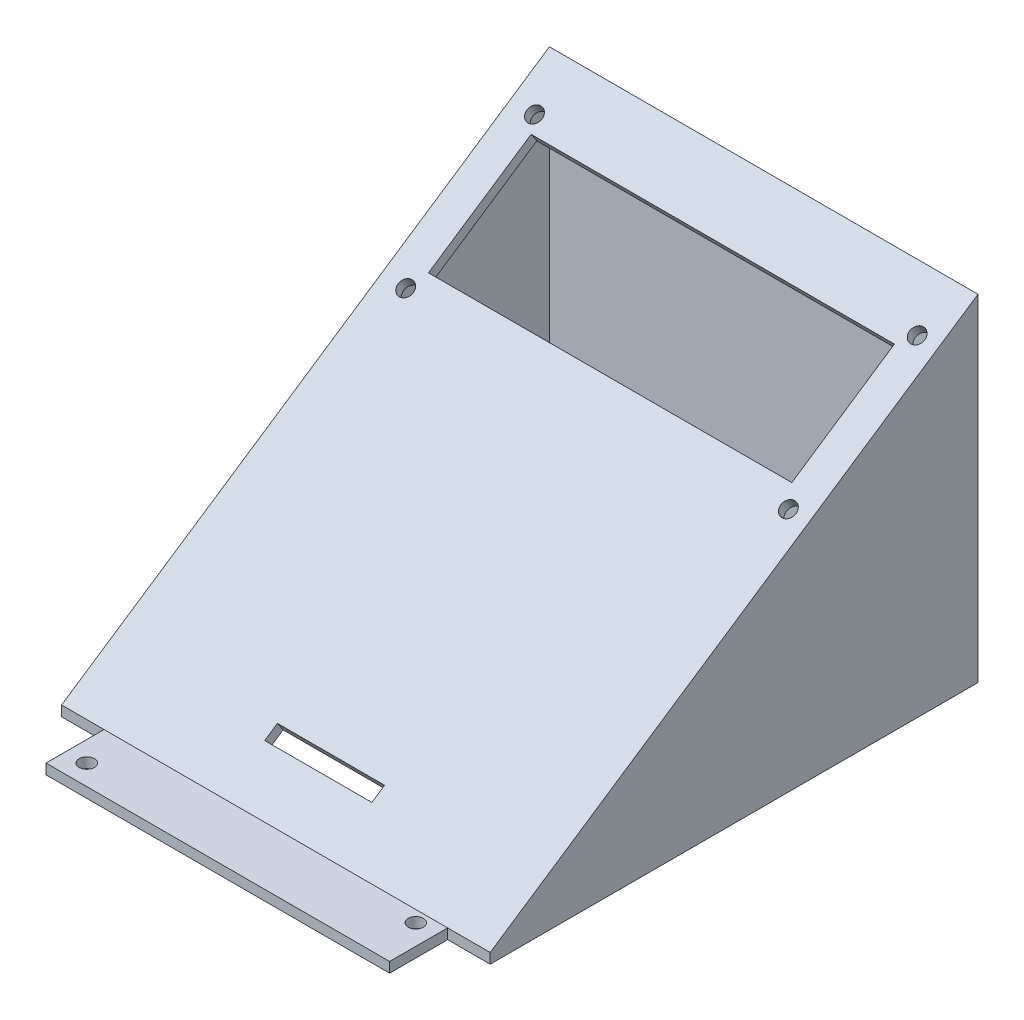
from build123d import *

# Parameters (mm, degrees)
SKETCH1_W           = 67.34
SKETCH1_H           = 113.06
SKETCH1_R           = 1.5
SKETCH1_W_2         = 55.34
SKETCH1_H_2         = 101.06
BOSS_EXTRUDE1_DEPTH = 2
BOSS_EXTRUDE2_DEPTH = 42
SKETCH4_W           = 55.34
SKETCH4_H           = 2
BOSS_EXTRUDE5_DEPTH = 11.970099
CUT_EXTRUDE1_REACH  = 60.174
SKETCH5_R           = 1.5
SKETCH5_W           = 71.2
SKETCH5_H           = 24.2
SKETCH5_W_2         = 21
SKETCH5_H_2         = 3
BOSS_EXTRUDE6_DEPTH = 2
SKETCH7_W           = 8.33
SKETCH7_H           = 95.603562999
BOSS_EXTRUDE7_DEPTH = 2
SKETCH8_W           = 55.34
SKETCH8_H           = 2
BOSS_EXTRUDE8_DEPTH = 2.076588


with BuildPart() as part:
    # Sketch1 → Boss-Extrude1 (new body)
    with BuildSketch(Plane(origin=(0, 0, 0), x_dir=(1, 0, 0), z_dir=(0, 1, 0))):
        with Locations((-64.664649644, -123.030692549)):
            Rectangle(SKETCH1_W, SKETCH1_H)
        with Locations((-34.994649644, -70.500692549)):
            Circle(SKETCH1_R, mode=Mode.SUBTRACT)
        with Locations((-94.334649644, -70.500692549)):
            Circle(SKETCH1_R, mode=Mode.SUBTRACT)
        with Locations((-94.334649644, -175.560692549)):
            Circle(SKETCH1_R, mode=Mode.SUBTRACT)
        with Locations((-34.994649644, -170.434906111)):
            Circle(SKETCH1_R, mode=Mode.SUBTRACT)
        with Locations((-64.664649644, -123.030692549)):
            Rectangle(SKETCH1_W_2, SKETCH1_H_2, mode=Mode.SUBTRACT)
    extrude(amount=BOSS_EXTRUDE1_DEPTH)

    # Sketch3 → Boss-Extrude2 (add, symmetric)
    with BuildSketch(Plane(origin=(-64.664649644, 0, 0), x_dir=(0, 0, -1), z_dir=(1, 0, 0))):
        Polygon((-161.590593962, 4), (-161.590593962, 2), (-168.180843703, 2), (-72.577280704, 65.913681963), (-72.577280704, 2), (-74.577280704, 2), (-74.577280704, 4), (-74.577280704, 62.1708574), align=None)
    extrude(amount=BOSS_EXTRUDE2_DEPTH, both=True)

    # Sketch4 → Boss-Extrude5 (add)
    with BuildSketch(Plane(origin=(0, 0, 173.560692549), x_dir=(-1, 0, 0), z_dir=(0, 0, -1))):
        with Locations((64.664649644, 1)):
            Rectangle(SKETCH4_W, SKETCH4_H)
    extrude(amount=BOSS_EXTRUDE5_DEPTH)

    # Sketch5 → Cut-Extrude1 (cut, up to next)
    with BuildSketch(Plane(origin=(0, 79.087200487, 52.872027158), x_dir=(1, 0, 0), z_dir=(0, 0.83133533, 0.555771148)), mode=Mode.PRIVATE) as cut_extrude1_sk1:
        with Locations((-26.824649644, -33.033134975)):
            Circle(SKETCH5_R)
    cut_extrude1_tool1 = extrude(cut_extrude1_sk1.sketch, amount=-CUT_EXTRUDE1_REACH, mode=Mode.PRIVATE) & part.part
    add(cut_extrude1_tool1.solids().sort_by_distance((-26.82465, 60.728337, 80.333639))[0], mode=Mode.SUBTRACT)
    # Sketch5 → Cut-Extrude1 (cut, up to next)
    with BuildSketch(Plane(origin=(0, 79.087200487, 52.872027158), x_dir=(1, 0, 0), z_dir=(0, 0.83133533, 0.555771148)), mode=Mode.PRIVATE) as cut_extrude1_sk2:
        with Locations((-26.824649644, -63.403134975)):
            Circle(SKETCH5_R)
    cut_extrude1_tool2 = extrude(cut_extrude1_sk2.sketch, amount=-CUT_EXTRUDE1_REACH, mode=Mode.PRIVATE) & part.part
    add(cut_extrude1_tool2.solids().sort_by_distance((-26.82465, 43.849567, 105.581293))[0], mode=Mode.SUBTRACT)
    # Sketch5 → Cut-Extrude1 (cut, up to next)
    with BuildSketch(Plane(origin=(0, 79.087200487, 52.872027158), x_dir=(1, 0, 0), z_dir=(0, 0.83133533, 0.555771148)), mode=Mode.PRIVATE) as cut_extrude1_sk3:
        with Locations((-101.824649644, -63.403134975)):
            Circle(SKETCH5_R)
    cut_extrude1_tool3 = extrude(cut_extrude1_sk3.sketch, amount=-CUT_EXTRUDE1_REACH, mode=Mode.PRIVATE) & part.part
    add(cut_extrude1_tool3.solids().sort_by_distance((-101.82465, 43.849567, 105.581293))[0], mode=Mode.SUBTRACT)
    # Sketch5 → Cut-Extrude1 (cut, up to next)
    with BuildSketch(Plane(origin=(0, 79.087200487, 52.872027158), x_dir=(1, 0, 0), z_dir=(0, 0.83133533, 0.555771148)), mode=Mode.PRIVATE) as cut_extrude1_sk4:
        with Locations((-101.824649644, -33.033134975)):
            Circle(SKETCH5_R)
    cut_extrude1_tool4 = extrude(cut_extrude1_sk4.sketch, amount=-CUT_EXTRUDE1_REACH, mode=Mode.PRIVATE) & part.part
    add(cut_extrude1_tool4.solids().sort_by_distance((-101.82465, 60.728337, 80.333639))[0], mode=Mode.SUBTRACT)
    # Sketch5 → Cut-Extrude1 (cut, up to next)
    with BuildSketch(Plane(origin=(0, 79.087200487, 52.872027158), x_dir=(1, 0, 0), z_dir=(0, 0.83133533, 0.555771148)), mode=Mode.PRIVATE) as cut_extrude1_sk5:
        with Locations((-64.664649644, -47.803134975)):
            Rectangle(SKETCH5_W, SKETCH5_H)
    cut_extrude1_tool5 = extrude(cut_extrude1_sk5.sketch, amount=-CUT_EXTRUDE1_REACH, mode=Mode.PRIVATE) & part.part
    add(cut_extrude1_tool5.solids().sort_by_distance((-64.66465, 52.519597, 92.612462))[0], mode=Mode.SUBTRACT)
    # Sketch5 → Cut-Extrude1 (cut, up to next)
    with BuildSketch(Plane(origin=(0, 79.087200487, 52.872027158), x_dir=(1, 0, 0), z_dir=(0, 0.83133533, 0.555771148)), mode=Mode.PRIVATE) as cut_extrude1_sk6:
        with Locations((-64.664649644, -127.203134975)):
            Rectangle(SKETCH5_W_2, SKETCH5_H_2)
    cut_extrude1_tool6 = extrude(cut_extrude1_sk6.sketch, amount=-CUT_EXTRUDE1_REACH, mode=Mode.PRIVATE) & part.part
    add(cut_extrude1_tool6.solids().sort_by_distance((-64.66465, 8.391368, 158.620487))[0], mode=Mode.SUBTRACT)

    # Sketch6 → Boss-Extrude6 (add)
    with BuildSketch(Plane(origin=(-22.664649644, 0, 0), x_dir=(0, 0, -1), z_dir=(1, 0, 0))):
        Polygon((-168.180843703, 2), (-168.180843703, 0), (-72.577280704, 0), (-72.577280704, 2), (-72.577280704, 65.913681963), align=None)
    boss_extrude6 = extrude(amount=-BOSS_EXTRUDE6_DEPTH)

    # Sketch7 → Boss-Extrude7 (add)
    with BuildSketch(Plane.XZ.offset(-2)):
        with Locations((-28.829649644, 120.379062204)):
            Rectangle(SKETCH7_W, SKETCH7_H)
    boss_extrude7 = extrude(amount=BOSS_EXTRUDE7_DEPTH)

    # Mirror1: Boss-Extrude6, Boss-Extrude7 across plane
    add(boss_extrude6.mirror(Plane(origin=(-64.664649644, 0, 0), x_dir=(0, 0, 1), z_dir=(1, 0, 0))))
    add(boss_extrude7.mirror(Plane(origin=(-64.664649644, 0, 0), x_dir=(0, 0, 1), z_dir=(1, 0, 0))))

    # Sketch8 → Boss-Extrude8 (add)
    with BuildSketch(Plane.XY.offset(72.500692549)):
        with Locations((-64.664649644, 1)):
            Rectangle(SKETCH8_W, SKETCH8_H)
    extrude(amount=BOSS_EXTRUDE8_DEPTH)


solid = part.part
